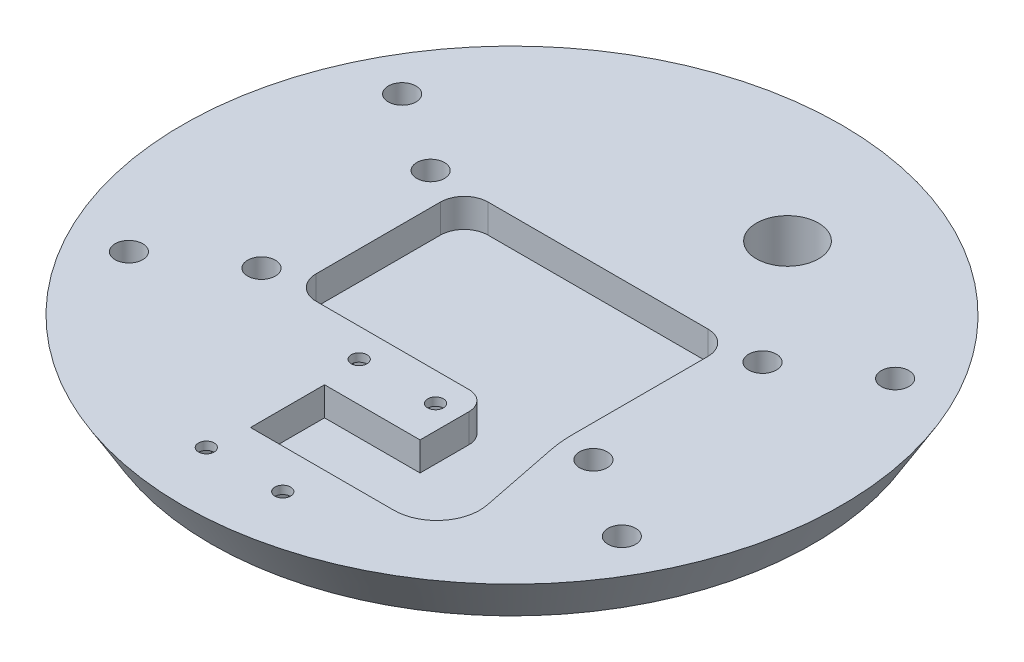
from build123d import *

# Parameters (mm, degrees)
SKETCH4_R          = 1.65
CUT_EXTRUDE1_DEPTH = 4
CUT_EXTRUDE2_START = 4
SKETCH5_R          = 2.9
CUT_EXTRUDE2_DEPTH = 15
SKETCH7_R          = 6.5
CUT_EXTRUDE4_DEPTH = 10
SKETCH10_R         = 1.65
CUT_EXTRUDE5_DEPTH = 6
CUT_EXTRUDE6_START = -1.7
CUT_EXTRUDE6_DEPTH = 2.6


with BuildPart() as part:
    # Sketch1 → Revolve1 (revolve)
    with BuildSketch(Plane.XY):
        Polygon((0, 0), (63, 0), (69, 10), (0, 10), align=None)
    revolve(axis=Axis((0, 10, 0), (0, -1, 0)))

    # Sketch4 → Cut-Extrude1 (cut)
    with BuildSketch(Plane(origin=(0, 0, 0), x_dir=(1, 0, 0), z_dir=(0, 1, 0))):
        with Locations((34.749254443, 17.70562949)):
            Circle(SKETCH4_R)
        with Locations((51.602562721, 28.603767595)):
            Circle(SKETCH4_R)
        with Locations((51.602562721, -28.603767595)):
            Circle(SKETCH4_R)
        with Locations((34.749254443, -17.70562949)):
            Circle(SKETCH4_R)
        with Locations((-34.749254443, -17.70562949)):
            Circle(SKETCH4_R)
        with Locations((-51.602562721, -28.603767595)):
            Circle(SKETCH4_R)
        with Locations((-51.602562721, 28.603767595)):
            Circle(SKETCH4_R)
        with Locations((-34.749254443, 17.70562949)):
            Circle(SKETCH4_R)
    extrude(amount=CUT_EXTRUDE1_DEPTH, mode=Mode.SUBTRACT)

    # Sketch5 → Cut-Extrude2 (cut, through all)
    with BuildSketch(Plane(origin=(0, 0, 0), x_dir=(-1, 0, 0), z_dir=(0, -1, 0)).offset(CUT_EXTRUDE2_START)):
        with Locations((-51.602562721, 28.603767595)):
            Circle(SKETCH5_R)
        with Locations((-51.602562721, -28.603767595)):
            Circle(SKETCH5_R)
        with Locations((51.602562721, -28.603767595)):
            Circle(SKETCH5_R)
        with Locations((51.602562721, 28.603767595)):
            Circle(SKETCH5_R)
        with Locations((-34.749254443, 17.70562949)):
            Circle(SKETCH5_R)
        with Locations((-34.749254443, -17.70562949)):
            Circle(SKETCH5_R)
        with Locations((34.749254443, -17.70562949)):
            Circle(SKETCH5_R)
        with Locations((34.749254443, 17.70562949)):
            Circle(SKETCH5_R)
    extrude(amount=-CUT_EXTRUDE2_DEPTH, mode=Mode.SUBTRACT)

    # Sketch7 → Cut-Extrude4 (cut)
    with BuildSketch(Plane(origin=(0, 0, 0), x_dir=(-1, 0, 0), z_dir=(0, -1, 0))):
        with Locations((-15.39090645, 42.286167935)):
            Circle(SKETCH7_R)
    extrude(amount=-CUT_EXTRUDE4_DEPTH, mode=Mode.SUBTRACT)

    # Sketch10 → Cut-Extrude5 (cut)
    with BuildSketch(Plane(origin=(0, 10, 0), x_dir=(-1, 0, 0), z_dir=(0, 1, 0))):
        with Locations((-8, 56)):
            Circle(SKETCH10_R)
        with Locations((8, 56)):
            Circle(SKETCH10_R)
        with Locations((8, 24)):
            Circle(SKETCH10_R)
        with Locations((-8, 24)):
            Circle(SKETCH10_R)
        with BuildLine():
            Line((-13, 32.25), (7, 32.25))
            Line((7, 32.25), (7, 47.75))
            Line((7, 47.75), (-23, 47.75))
            ThreePointArc((-23, 47.75), (-29.960784303, 44.455040042), (-31.824789595, 36.982773752))
            Line((-31.824789595, 36.982773752), (-28.486695571, 20.31372674))
            ThreePointArc((-28.486695571, 20.31372674), (-28.121971433, 17.871279613), (-28, 15.40476494))
            Line((-28, 15.40476494), (-28, -13))
            ThreePointArc((-28, -13), (-26.535533906, -16.535533906), (-23, -18))
            Line((-23, -18), (23, -18))
            ThreePointArc((23, -18), (26.535533906, -16.535533906), (28, -13))
            Line((28, -13), (28, 13))
            ThreePointArc((28, 13), (26.535533906, 16.535533906), (23, 18))
            Line((23, 18), (-9, 18))
            ThreePointArc((-9, 18), (-11.828427125, 19.171572875), (-13, 22))
            Line((-13, 22), (-13, 32.25))
        make_face()
    extrude(amount=-CUT_EXTRUDE5_DEPTH, mode=Mode.SUBTRACT)

    # Sketch11 → Cut-Extrude6 (cut)
    with BuildSketch(Plane(origin=(0, 10, 0), x_dir=(-1, 0, 0), z_dir=(0, 1, 0)).offset(CUT_EXTRUDE6_START)):
        Polygon((-4.651368439, 56), (-6.325684219, 58.9), (-9.674315781, 58.9), (-11.348631561, 56), (-9.674315781, 53.1), (-6.325684219, 53.1), align=None)
        Polygon((11.347570698, 56.084283782), (9.600793452, 58.941223157), (6.253222754, 58.856939374), (4.652429302, 55.915716218), (6.399206548, 53.058776843), (9.746777246, 53.143060626), align=None)
        Polygon((-5.1, 25.674315781), (-8, 27.348631561), (-10.9, 25.674315781), (-10.9, 22.325684219), (-8, 20.651368439), (-5.1, 22.325684219), align=None)
        Polygon((10.898923771, 22.323821518), (10.901075032, 25.672452388), (8.002151261, 27.34863087), (5.101076229, 25.676178482), (5.098924968, 22.327547612), (7.997848739, 20.65136913), align=None)
    extrude(amount=-CUT_EXTRUDE6_DEPTH, mode=Mode.SUBTRACT)


solid = part.part
